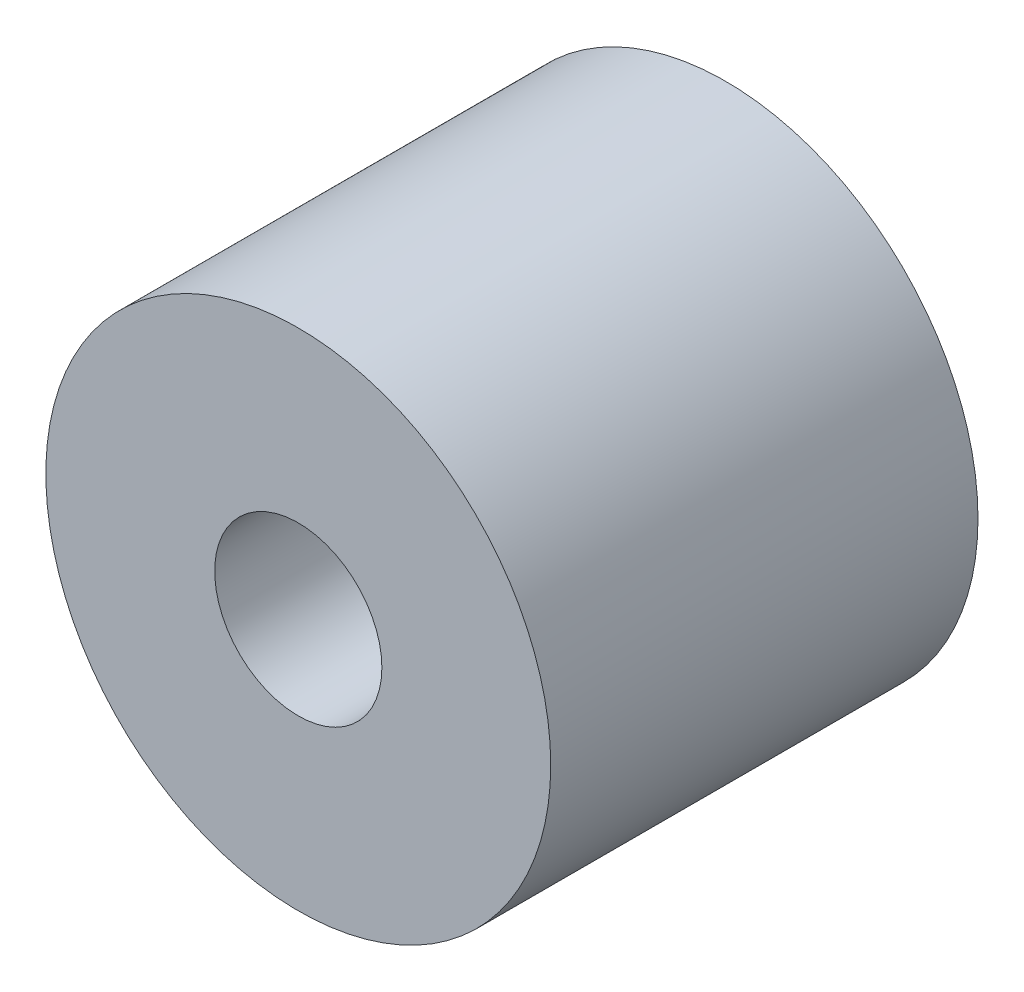
from build123d import *

# Parameters (mm, degrees)
SKETCH1_R           = 118.11
SKETCH1_R_2         = 39.116
BOSS_EXTRUDE1_DEPTH = 199.898


with BuildPart() as part:
    # Sketch1 → Boss-Extrude1 (new body)
    with BuildSketch(Plane.XY):
        Circle(SKETCH1_R)
        Circle(SKETCH1_R_2, mode=Mode.SUBTRACT)
    extrude(amount=BOSS_EXTRUDE1_DEPTH)


solid = part.part
